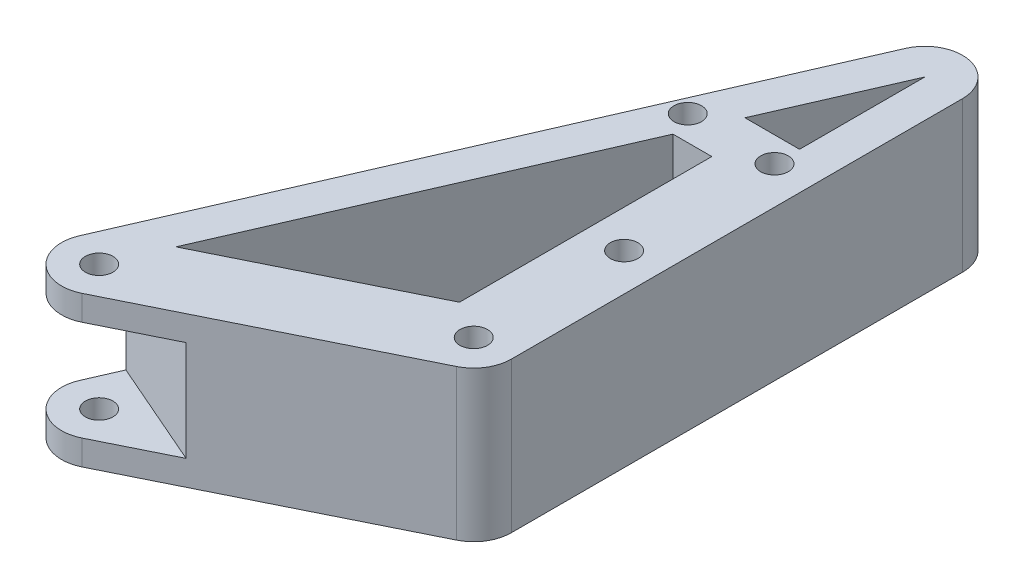
from build123d import *

# Parameters (mm, degrees)
SKETCH1_R           = 2.75
BOSS_EXTRUDE1_DEPTH = 30
SKETCH4_W           = 7
SKETCH4_H           = 20
SKETCH4_W_2         = 13.969977059
CUT_EXTRUDE2_DEPTH  = 34


with BuildPart() as part:
    # Sketch1 → Boss-Extrude1 (new body)
    with BuildSketch(Plane(origin=(0, 0, 0), x_dir=(1, 0, 0), z_dir=(0, 1, 0))):
        with BuildLine():
            Line((-46.676005757, -6.723173527), (3.323994243, 17.99725225))
            ThreePointArc((3.323994243, 17.99725225), (6.37102648, 20.763151262), (7.5, 24.720425777))
            Line((7.5, 24.720425777), (7.5, 114.720425777))
            ThreePointArc((7.5, 114.720425777), (1.53049147, 122.062605008), (-6.875358896, 117.716997159))
            Line((-6.875358896, 117.716997159), (-56.875358896, 2.996571382))
            ThreePointArc((-56.875358896, 2.996571382), (-55.174109392, -5.429419122), (-46.676005757, -6.723173527))
        make_face()
        with Locations((-50, 0)):
            Circle(SKETCH1_R, mode=Mode.SUBTRACT)
        Polygon((-7.5, 29.378946496), (-45.351897452, 10.664646067), (-15.254476159, 79.720425777), (-7.5, 79.720425777), align=None, mode=Mode.SUBTRACT)
        with Locations((0, 54.720425777)):
            Circle(SKETCH1_R, mode=Mode.SUBTRACT)
        with Locations((-17.304325397, 84.720425777)):
            Circle(SKETCH1_R, mode=Mode.SUBTRACT)
        with Locations((0, 84.720425777)):
            Circle(SKETCH1_R, mode=Mode.SUBTRACT)
        Polygon((-10.8960544, 89.720425777), (0, 114.720425777), (0, 89.720425777), align=None, mode=Mode.SUBTRACT)
        with Locations((0, 24.720425777)):
            Circle(SKETCH1_R, mode=Mode.SUBTRACT)
    extrude(amount=BOSS_EXTRUDE1_DEPTH)

    # Sketch4 → Cut-Extrude2 (cut)
    with BuildSketch(Plane(origin=(-48.89363441, 0, -21.309908013), x_dir=(-0.399542851, 0, 0.91671452), z_dir=(-0.91671452, 0, -0.399542851))):
        with Locations((16.477142547, 15)):
            Rectangle(SKETCH4_W, SKETCH4_H)
        with Locations((26.962131077, 15)):
            Rectangle(SKETCH4_W_2, SKETCH4_H)
    extrude(amount=-CUT_EXTRUDE2_DEPTH, mode=Mode.SUBTRACT)


solid = part.part
